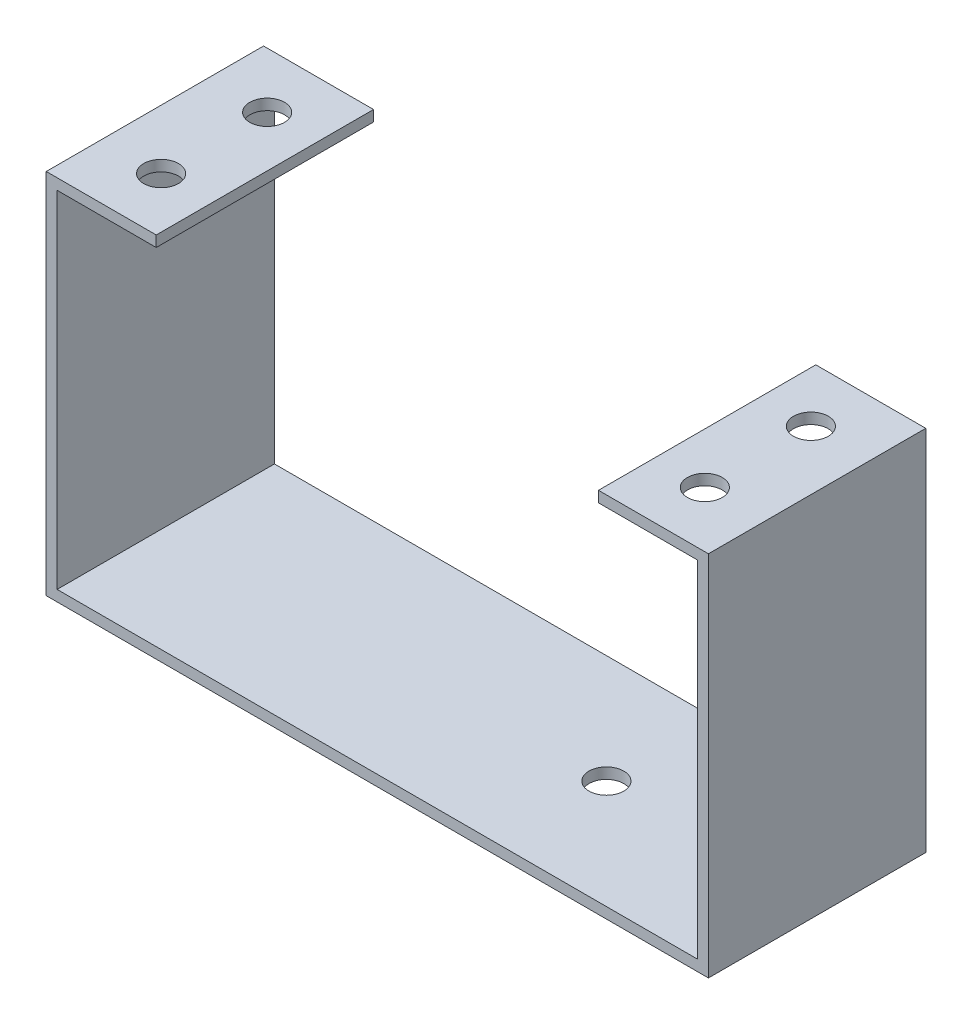
from build123d import *

# Parameters (mm, degrees)
SKETCH_2_W          = 60.94
SKETCH_2_H          = 20
EXTRUDE_1_DEPTH     = 1
SKETCH_3_W          = 1
SKETCH_3_H          = 20
EXTRUDE_2_DEPTH     = 32.81
SKETCH_4_W          = 1
SKETCH_4_H          = 20
EXTRUDE_3_DEPTH     = 32.81
SKETCH_9_W          = 20
SKETCH_9_H          = 1
EXTRUDE_8_DEPTH     = 9.12
SKETCH_10_W         = 20
SKETCH_10_H         = 1
EXTRUDE_9_DEPTH     = 9.12
SKETCH_13_R         = 1.6
CUT_EXTRUDE_2_DEPTH = 1
SKETCH_14_R         = 1.6
CUT_EXTRUDE_3_DEPTH = 1
SKETCH_15_R         = 1.6
CUT_EXTRUDE_4_DEPTH = 1
SKETCH_16_R         = 1.6
CUT_EXTRUDE_5_DEPTH = 1
SKETCH_17_R         = 1.6
CUT_EXTRUDE_6_DEPTH = 1


with BuildPart() as part:
    # ｽｹｯﾁ2 → ﾎﾞｽ - 押し出し1 (new body)
    with BuildSketch(Plane(origin=(0, 0, 0), x_dir=(1, 0, 0), z_dir=(0, 1, 0))):
        with Locations((30.47, 10)):
            Rectangle(SKETCH_2_W, SKETCH_2_H)
    extrude(amount=EXTRUDE_1_DEPTH)

    # ｽｹｯﾁ3 → ﾎﾞｽ - 押し出し2 (add)
    with BuildSketch(Plane(origin=(0, 1, 0), x_dir=(1, 0, 0), z_dir=(0, 1, 0))):
        with Locations((60.44, 10)):
            Rectangle(SKETCH_3_W, SKETCH_3_H)
    extrude(amount=EXTRUDE_2_DEPTH)

    # ｽｹｯﾁ4 → ﾎﾞｽ - 押し出し3 (add)
    with BuildSketch(Plane(origin=(0, 1, 0), x_dir=(1, 0, 0), z_dir=(0, 1, 0))):
        with Locations((0.5, 10)):
            Rectangle(SKETCH_4_W, SKETCH_4_H)
    extrude(amount=EXTRUDE_3_DEPTH)

    # ｽｹｯﾁ9 → ﾎﾞｽ - 押し出し8 (add)
    with BuildSketch(Plane.ZY.offset(-59.94)):
        with Locations((-10, 33.31)):
            Rectangle(SKETCH_9_W, SKETCH_9_H)
    extrude(amount=EXTRUDE_8_DEPTH)

    # ｽｹｯﾁ10 → ﾎﾞｽ - 押し出し9 (add)
    with BuildSketch(Plane(origin=(1, 0, 0), x_dir=(0, 0, -1), z_dir=(1, 0, 0))):
        with Locations((10, 33.31)):
            Rectangle(SKETCH_10_W, SKETCH_10_H)
    extrude(amount=EXTRUDE_9_DEPTH)

    # ｽｹｯﾁ13 → ｶｯﾄ - 押し出し2 (cut)
    with BuildSketch(Plane(origin=(0, 33.81, 0), x_dir=(1, 0, 0), z_dir=(0, 1, 0))):
        with Locations((55.49, 5.12)):
            Circle(SKETCH_13_R)
    extrude(amount=-CUT_EXTRUDE_2_DEPTH, mode=Mode.SUBTRACT)

    # ｽｹｯﾁ14 → ｶｯﾄ - 押し出し3 (cut)
    with BuildSketch(Plane(origin=(0, 33.81, 0), x_dir=(1, 0, 0), z_dir=(0, 1, 0))):
        with Locations((55.49, 14.88)):
            Circle(SKETCH_14_R)
    extrude(amount=-CUT_EXTRUDE_3_DEPTH, mode=Mode.SUBTRACT)

    # ｽｹｯﾁ15 → ｶｯﾄ - 押し出し4 (cut)
    with BuildSketch(Plane(origin=(0, 33.81, 0), x_dir=(1, 0, 0), z_dir=(0, 1, 0))):
        with Locations((5.45, 5.12)):
            Circle(SKETCH_15_R)
    extrude(amount=-CUT_EXTRUDE_4_DEPTH, mode=Mode.SUBTRACT)

    # ｽｹｯﾁ16 → ｶｯﾄ - 押し出し5 (cut)
    with BuildSketch(Plane(origin=(0, 33.81, 0), x_dir=(1, 0, 0), z_dir=(0, 1, 0))):
        with Locations((5.45, 14.88)):
            Circle(SKETCH_16_R)
    extrude(amount=-CUT_EXTRUDE_5_DEPTH, mode=Mode.SUBTRACT)

    # ｽｹｯﾁ17 → ｶｯﾄ - 押し出し6 (cut)
    with BuildSketch(Plane(origin=(0, 0, 0), x_dir=(-1, 0, 0), z_dir=(0, -1, 0))):
        with Locations((-41.55, 10)):
            Circle(SKETCH_17_R)
    extrude(amount=-CUT_EXTRUDE_6_DEPTH, mode=Mode.SUBTRACT)


solid = part.part
